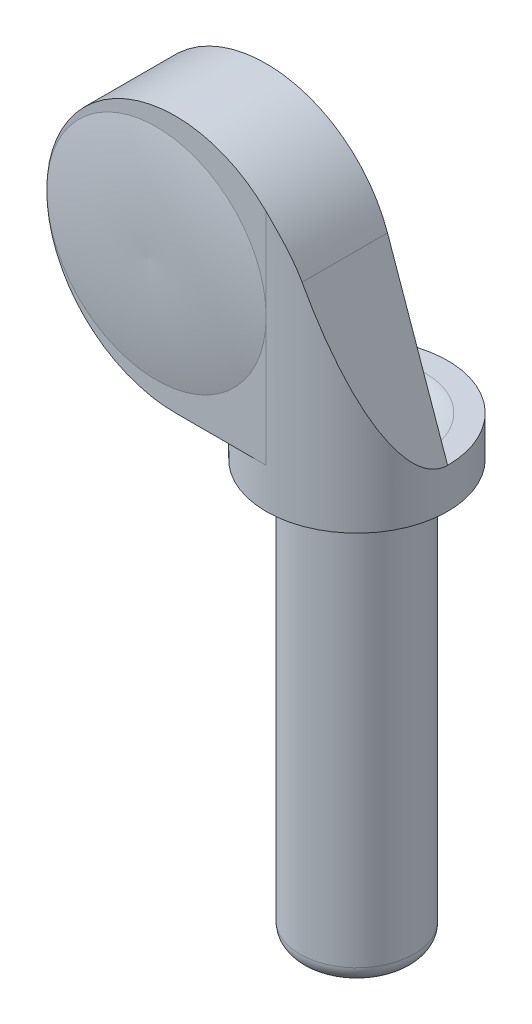
from build123d import *

# Parameters (mm, degrees)
SKETCH_1_R           = 2
EXTRUDE_1_DEPTH      = 16
EXTRUDE_2_DEPTH      = 3.175
SKETCH_4_R           = 3.15
CUT_EXTRUDE_6_DEPTH  = 2.775
FILLET_3_R           = 0.6
SKETCH_7_R           = 3.175
EXTRUDE_3_DEPTH      = 1.4
CUT_EXTRUDE_10_DEPTH = 10
FILLET_4_R           = 0.3
CUT_EXTRUDE_11_REACH = 18
FILLET_5_R           = 1


with BuildPart() as part:
    # 草图1 → 凸台-拉伸1 (new body)
    with BuildSketch(Plane(origin=(0, 0, 0), x_dir=(1, 0, 0), z_dir=(0, 1, 0))):
        Circle(SKETCH_1_R)
    extrude(amount=EXTRUDE_1_DEPTH)

    # 草图2 → 凸台-拉伸2 (add)
    with BuildSketch(Plane.XY):
        with BuildLine():
            Line((3.175, 16), (1.070738578, 21.991208882))
            ThreePointArc((1.070738578, 21.991208882), (-6.846541908, 23.101880092), (-3.175, 16))
            Line((-3.175, 16), (3.175, 16))
        make_face()
    extrude(amount=EXTRUDE_2_DEPTH)

    # 草图4 → 切除-拉伸6 (cut)
    with BuildSketch(Plane(origin=(0, 0, 0), x_dir=(-1, 0, 0), z_dir=(0, 0, -1))):
        with Locations((3.175, 20.5)):
            Circle(SKETCH_4_R)
    extrude(amount=-CUT_EXTRUDE_6_DEPTH, mode=Mode.SUBTRACT)

    # 圆角3
    fillet_3_edges = [part.edges().sort_by_distance(p)[0] for p in [
        (-2, 0, 0),
    ]]
    fillet(fillet_3_edges, radius=FILLET_3_R)

    # 草图7 → 凸台-拉伸3 (add)
    with BuildSketch(Plane(origin=(0, 16, 0), x_dir=(1, 0, 0), z_dir=(0, 1, 0))):
        Circle(SKETCH_7_R)
    extrude(amount=-EXTRUDE_3_DEPTH)

    # 草图11 → 切除-拉伸10 (cut, through all)
    with BuildSketch(Plane.XZ.offset(-16)):
        with BuildLine():
            Line((3.175, 3.175), (3.50604204, 0.275))
            Line((3.50604204, 0.275), (3.175, 0))
            ThreePointArc((3.175, 0), (2.24506403, 2.24506403), (0, 3.175))
            Line((0, 3.175), (3.175, 3.175))
        make_face()
    extrude(amount=-CUT_EXTRUDE_10_DEPTH, mode=Mode.SUBTRACT)

    # 草图12 → 旋转1 (revolve)
    with BuildSketch(Plane(origin=(0, 20.5, 0), x_dir=(-1, 0, 0), z_dir=(0, -1, 0))):
        with BuildLine():
            Line((3.8375, -3.175), (3.8375, -3.475))
            ThreePointArc((3.8375, -3.475), (5.765394552, -3.441974066), (7.675, -3.175))
            Line((7.675, -3.175), (3.8375, -3.175))
        make_face()
    revolve(axis=Axis((-3.8375, 20.5, 3.175), (0, 0, 1)))

    # 圆角4
    fillet_4_edges = [part.edges().sort_by_distance(p)[0] for p in [
        (-0.025, 20.5, 0),
    ]]
    fillet(fillet_4_edges, radius=FILLET_4_R)

    # 草图13 → 切除-拉伸11 (cut, up to next)
    with BuildSketch(Plane(origin=(0, 16, 0), x_dir=(1, 0, 0), z_dir=(0, 1, 0)), mode=Mode.PRIVATE) as cut_extrude_11_sk1:
        with BuildLine():
            Line((-1.4, 0), (1.4, 0))
            ThreePointArc((1.4, 0), (0, 1.4), (-1.4, 0))
        make_face()
    cut_extrude_11_tool1 = extrude(cut_extrude_11_sk1.sketch, amount=-CUT_EXTRUDE_11_REACH, mode=Mode.PRIVATE) & part.part
    add(cut_extrude_11_tool1.solids().sort_by_distance((0, 16, -0.594178))[0], mode=Mode.SUBTRACT)

    # 圆角5
    fillet_5_edges = [part.edges().sort_by_distance(p)[0] for p in [
        (0, 16, -1.4),
    ]]
    fillet(fillet_5_edges, radius=FILLET_5_R)


solid = part.part
